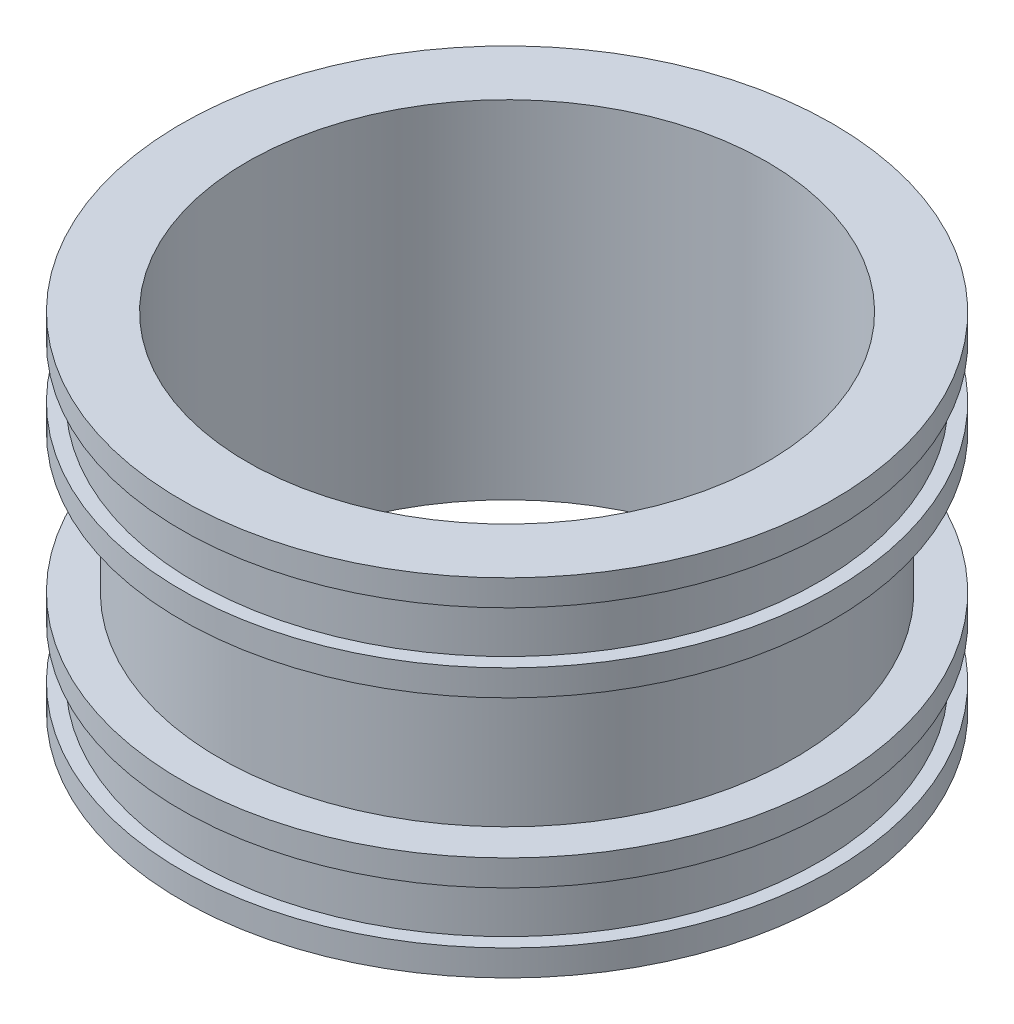
from build123d import *


with BuildPart() as part:
    # Esboço1 → Revolução1 (revolve)
    with BuildSketch(Plane.XY):
        Polygon((75, 100), (94, 100), (94, 92.5), (90, 92.5), (90, 77.5), (94, 77.5), (94, 70), (83, 70), (83, 30), (94, 30), (94, 22.5), (90, 22.5), (90, 7.5), (94, 7.5), (94, 0), (75, 0), align=None)
    revolve(axis=Axis((0, 0, 0), (0, 1, 0)))


solid = part.part
